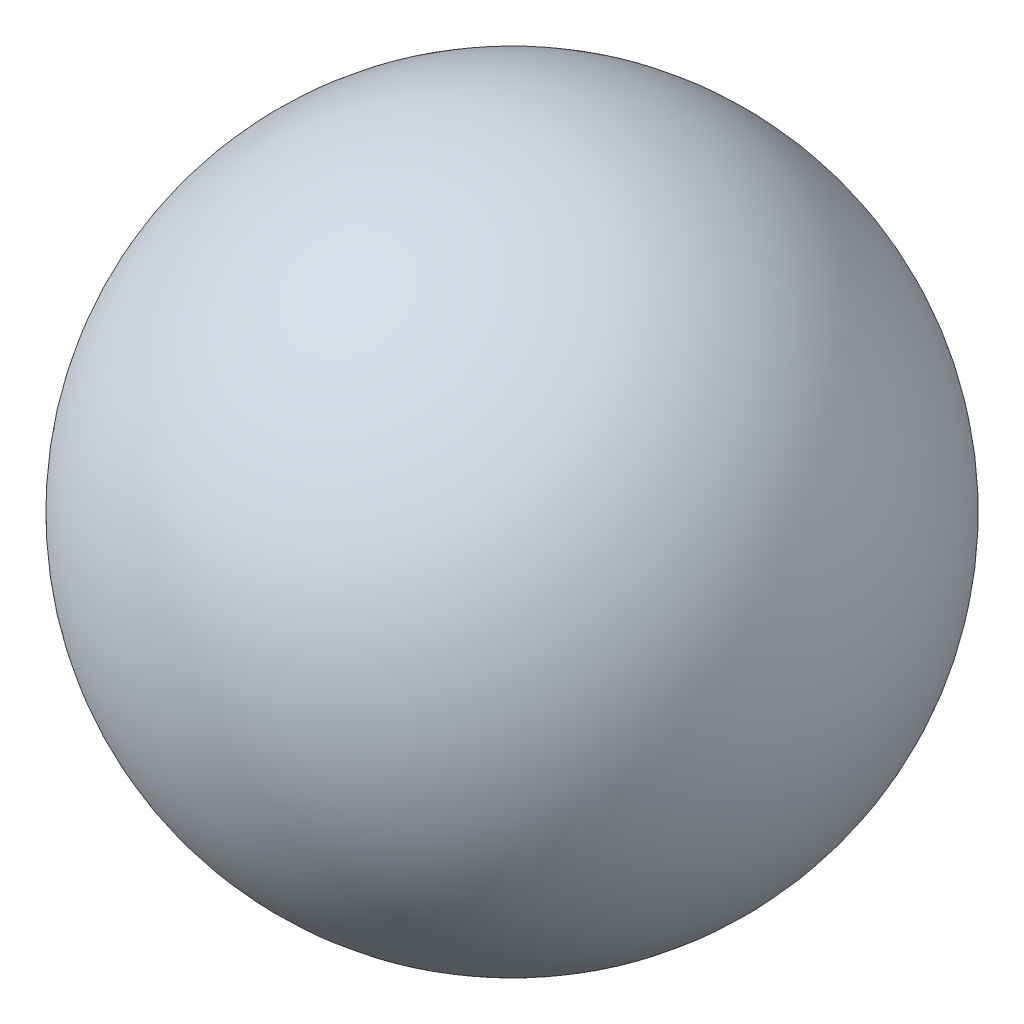
from build123d import *


with BuildPart() as part:
    # 草图1 → 旋转1 (revolve)
    with BuildSketch(Plane.XY):
        with BuildLine():
            Line((-1.760579704, 21), (-1.760579704, -21))
            ThreePointArc((-1.760579704, -21), (19.239420296, 0), (-1.760579704, 21))
        make_face()
    revolve(axis=Axis((-1.760579704, 21, 0), (0, -1, 0)))


solid = part.part
